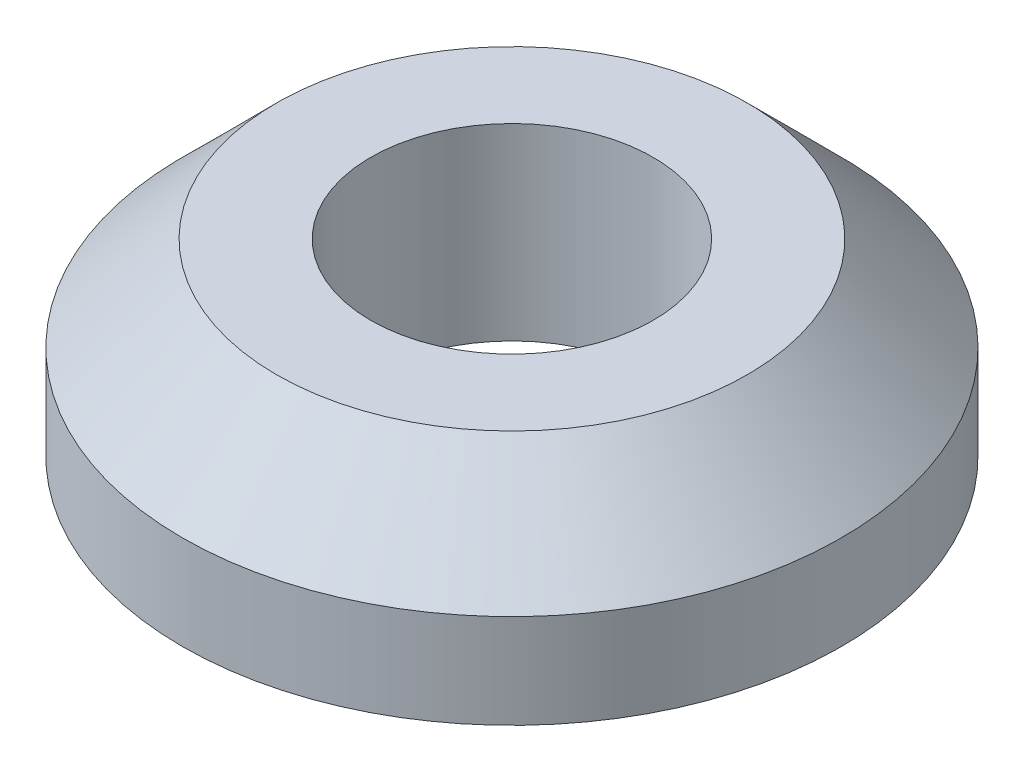
from build123d import *

# Parameters (mm, degrees)
SKETCH1_R           = 3.5
BOSS_EXTRUDE1_DEPTH = 2
CHAMFER1_SIZE       = 1
SKETCH2_R           = 1.5
CUT_EXTRUDE1_DEPTH  = 2


with BuildPart() as part:
    # Sketch1 → Boss-Extrude1 (new body)
    with BuildSketch(Plane(origin=(0, 0, 0), x_dir=(1, 0, 0), z_dir=(0, 1, 0))):
        Circle(SKETCH1_R)
    extrude(amount=BOSS_EXTRUDE1_DEPTH)

    # Chamfer1
    chamfer1_edges = [part.edges().sort_by_distance(p)[0] for p in [
        (-3.5, 2, 0),
    ]]
    chamfer(chamfer1_edges, length=CHAMFER1_SIZE)

    # Sketch2 → Cut-Extrude1 (cut)
    with BuildSketch(Plane(origin=(0, 2, 0), x_dir=(1, 0, 0), z_dir=(0, 1, 0))):
        Circle(SKETCH2_R)
    extrude(amount=-CUT_EXTRUDE1_DEPTH, mode=Mode.SUBTRACT)


solid = part.part
